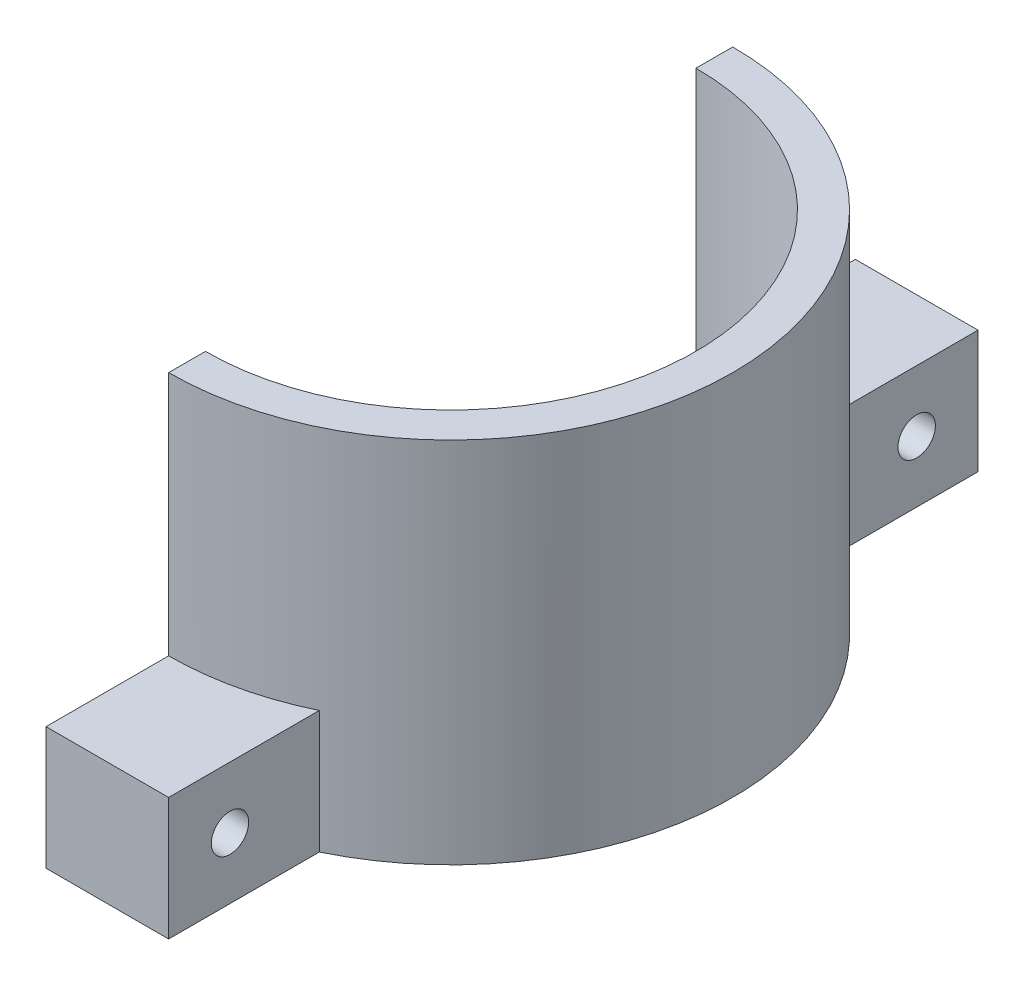
from build123d import *

# Parameters (mm, degrees)
TUBE_DEPTH         = 30
TERMINALS_DEPTH    = 10
CUT_EXTRUDE1_REACH = 25
SKETCH3_R          = 1.524


with BuildPart() as part:
    # Sketch1 → Tube (new body)
    with BuildSketch(Plane(origin=(0, 0, 0), x_dir=(1, 0, 0), z_dir=(0, 1, 0))):
        with BuildLine():
            Line((0, 23), (0, 20))
            ThreePointArc((0, 20), (20, 0), (0, -20))
            Line((0, -20), (0, -23))
            ThreePointArc((0, -23), (23, 0), (0, 23))
        make_face()
    extrude(amount=TUBE_DEPTH)

    # Sketch2 → Terminals (add)
    with BuildSketch(Plane(origin=(0, 0, 0), x_dir=(-1, 0, 0), z_dir=(0, -1, 0))):
        with BuildLine():
            Line((0, -23), (0, -33))
            Line((0, -33), (-10, -33))
            Line((-10, -33), (-10, -20.712315177))
            ThreePointArc((-10, -20.712315177), (-5.129169081, -22.420785547), (0, -23))
        make_face()
        with BuildLine():
            Line((0, 23), (0, 33))
            Line((0, 33), (-10, 33))
            Line((-10, 33), (-10, 20.712315177))
            ThreePointArc((-10, 20.712315177), (-5.129169081, 22.420785547), (0, 23))
        make_face()
    extrude(amount=-TERMINALS_DEPTH)

    # Sketch3 → Cut-Extrude1 (cut, up to next)
    with BuildSketch(Plane.ZY, mode=Mode.PRIVATE) as cut_extrude1_sk1:
        with Locations((-28, 5)):
            Circle(SKETCH3_R)
    cut_extrude1_tool1 = extrude(cut_extrude1_sk1.sketch, amount=-CUT_EXTRUDE1_REACH, mode=Mode.PRIVATE) & part.part
    add(cut_extrude1_tool1.solids().sort_by_distance((0, 5, -28))[0], mode=Mode.SUBTRACT)
    # Sketch3 → Cut-Extrude1 (cut, up to next)
    with BuildSketch(Plane.ZY, mode=Mode.PRIVATE) as cut_extrude1_sk2:
        with Locations((28, 5)):
            Circle(SKETCH3_R)
    cut_extrude1_tool2 = extrude(cut_extrude1_sk2.sketch, amount=-CUT_EXTRUDE1_REACH, mode=Mode.PRIVATE) & part.part
    add(cut_extrude1_tool2.solids().sort_by_distance((0, 5, 28))[0], mode=Mode.SUBTRACT)


solid = part.part
